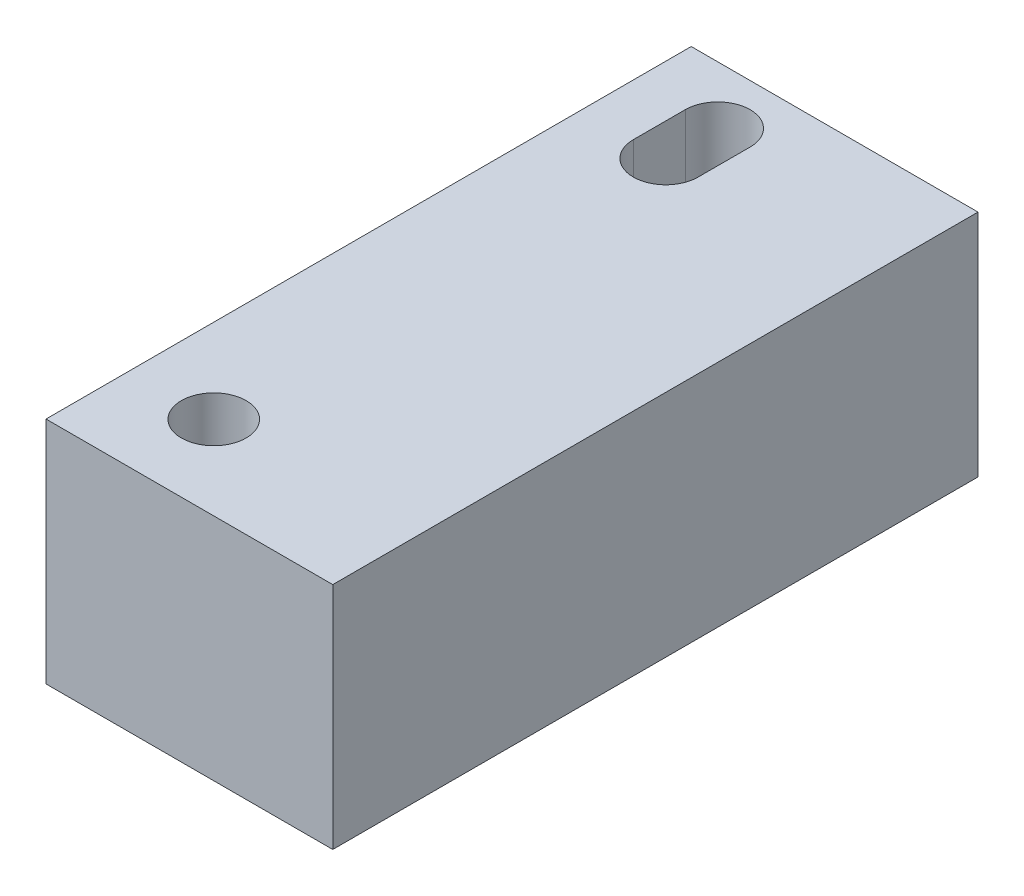
from build123d import *

# Parameters (mm, degrees)
SKETCH1_W                        = 19.05
SKETCH1_H                        = 42.8625
BOSS_EXTRUDE1_DEPTH              = 15.24
F_18_0_1695_DIAMETER_HOLE1_D     = 4.3053
F_18_0_1695_DIAMETER_HOLE1_DEPTH = 15.24
CUT_EXTRUDE1_REACH               = 17.24


with BuildPart() as part:
    # Sketch1 → Boss-Extrude1 (new body)
    with BuildSketch(Plane(origin=(0, 0, 0), x_dir=(1, 0, 0), z_dir=(0, 1, 0))):
        with Locations((-16.213580696, -1.598006412)):
            Rectangle(SKETCH1_W, SKETCH1_H)
    extrude(amount=BOSS_EXTRUDE1_DEPTH)

    # 18 _0.1695_ Diameter Hole1
    with Locations(Plane(origin=(0, 15.24, 0), x_dir=(-1, 0, 0), z_dir=(0, 1, 0))):
        with Locations((20.150580696, 17.473006412)):
            Hole(F_18_0_1695_DIAMETER_HOLE1_D / 2, depth=F_18_0_1695_DIAMETER_HOLE1_DEPTH)

    # Sketch4 → Cut-Extrude1 (cut, up to next)
    with BuildSketch(Plane(origin=(0, 15.24, 0), x_dir=(1, 0, 0), z_dir=(0, 1, 0)), mode=Mode.PRIVATE) as cut_extrude1_sk1:
        with BuildLine():
            Line((-17.997930696, 16.004193588), (-17.997930696, 12.549793588))
            ThreePointArc((-17.997930696, 12.549793588), (-20.150580696, 10.397143588), (-22.303230696, 12.549793588))
            Line((-22.303230696, 12.549793588), (-22.303230696, 16.004193588))
            ThreePointArc((-22.303230696, 16.004193588), (-20.150580696, 18.156843588), (-17.997930696, 16.004193588))
        make_face()
    cut_extrude1_tool1 = extrude(cut_extrude1_sk1.sketch, amount=-CUT_EXTRUDE1_REACH, mode=Mode.PRIVATE) & part.part
    add(cut_extrude1_tool1.solids().sort_by_distance((-20.150581, 15.24, -14.276994))[0], mode=Mode.SUBTRACT)


solid = part.part
